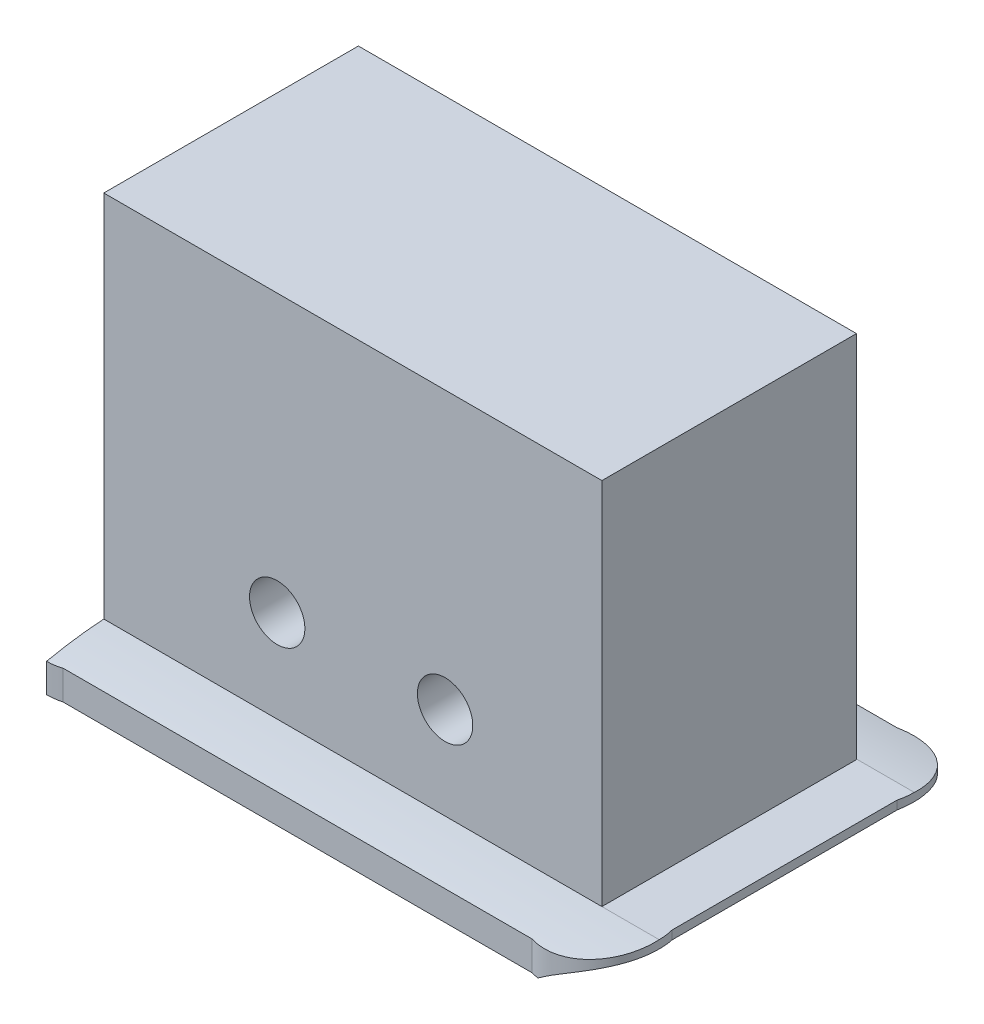
from build123d import *

# Parameters (mm, degrees)
SKETCH1_W               = 27
SKETCH1_H               = 13.8
SKETCH1_W_2             = 21
SKETCH1_H_2             = 7.8
BOSS_EXTRUDE1_DEPTH     = 22
SKETCH3_W               = 21
SKETCH3_H               = 7.8
BOSS_EXTRUDE2_DEPTH     = 2
SKETCH6_W               = 27
SKETCH6_H               = 13.8
BOSS_EXTRUDE3_DEPTH     = 2
SKETCH8_R               = 3
CUT_EXTRUDE2_DEPTH      = 5
CUT_EXTRUDE3_DEPTH      = 45
CUT_EXTRUDE5_DEPTH      = 45
CUT_EXTRUDE5_DEPTH_BACK = 45
SKETCH7_R               = 1.5
CUT_EXTRUDE6_DEPTH      = 4.10483504
CUT_EXTRUDE6_DEPTH_BACK = 17.904835039
SKETCH15_W              = 4.518403315
SKETCH15_H              = 4.307078744
CUT_EXTRUDE7_DEPTH      = 10
CUT_EXTRUDE7_DEPTH_BACK = 20


with BuildPart() as part:
    # Sketch1 → Boss-Extrude1 (new body)
    with BuildSketch(Plane(origin=(0, 0, 0), x_dir=(1, 0, 0), z_dir=(0, 1, 0))):
        with Locations((10.5, 3.9)):
            Rectangle(SKETCH1_W, SKETCH1_H)
        with Locations((10.5, 3.9)):
            Rectangle(SKETCH1_W_2, SKETCH1_H_2, mode=Mode.SUBTRACT)
    extrude(amount=BOSS_EXTRUDE1_DEPTH)

    # Sketch3 → Boss-Extrude2 (add)
    with BuildSketch(Plane(origin=(0, 22, 0), x_dir=(1, 0, 0), z_dir=(0, 1, 0))):
        with Locations((10.5, 3.9)):
            Rectangle(SKETCH3_W, SKETCH3_H)
    extrude(amount=-BOSS_EXTRUDE2_DEPTH)

    # Sketch6 → Boss-Extrude3 (add)
    with BuildSketch(Plane.XZ):
        with BuildLine():
            Line((-6, 2.2), (-6, -10))
            ThreePointArc((-6, -10), (-5.19544984, -12.99544984), (-2.2, -13.8))
            Line((-2.2, -13.8), (23.2, -13.8))
            ThreePointArc((23.2, -13.8), (26.19544984, -12.99544984), (27, -10))
            Line((27, -10), (27, 2.2))
            ThreePointArc((27, 2.2), (26.19544984, 5.19544984), (23.2, 6))
            Line((23.2, 6), (-2.2, 6))
            ThreePointArc((-2.2, 6), (-5.19544984, 5.19544984), (-6, 2.2))
        make_face()
        with Locations((10.5, -3.9)):
            Rectangle(SKETCH6_W, SKETCH6_H, mode=Mode.SUBTRACT)
    extrude(amount=-BOSS_EXTRUDE3_DEPTH)

    # Sketch8 → Cut-Extrude2 (cut)
    with BuildSketch(Plane.ZY.offset(3)):
        with Locations((-3.9, 16.816542633)):
            Circle(SKETCH8_R)
    extrude(amount=-CUT_EXTRUDE2_DEPTH, mode=Mode.SUBTRACT)

    # Sketch12 → Cut-Extrude3 (cut)
    with BuildSketch(Plane.ZY.offset(6)):
        with BuildLine():
            Line((3, 2), (6.104834939, 2))
            Line((6.104834939, 2), (6.104834939, 1.56677659))
            add(Edge.make_bspline(
                [(6.104834939, 1.56677659), (4.570942596, 1.898546139), (3, 2)],
                knots=[0, 0, 0, 1, 1, 1], degree=2))
        make_face()
        with BuildLine():
            Line((-13.933772202, 2), (-13.933772202, 1.56677659))
            add(Edge.make_bspline(
                [(-13.933772202, 1.56677659), (-12.399879859, 1.898546139), (-10.828937263, 2)],
                knots=[0, 0, 0, 1, 1, 1], degree=2))
            Line((-10.828937263, 2), (-13.933772202, 2))
        make_face()
    extrude(amount=-CUT_EXTRUDE3_DEPTH, mode=Mode.SUBTRACT)

    # Sketch13 → Cut-Extrude5 (cut, two sides)
    with BuildSketch(Plane(origin=(27, 0, -10), x_dir=(1, 0, 0), z_dir=(0, 0, 1))) as cut_extrude5_sk:
        with BuildLine():
            Line((-3.377880941, 0), (0.509598996, 0))
            Line((0.509598996, 0), (0.509598996, 1.57572602))
            Line((0.509598996, 1.57572602), (0.175576118, 1.57572602))
            add(Edge.make_bspline(
                [(-3.377880941, 0), (-2.337490472, 0.807111843), (-1.090367189, 1.274012221), (0.175576118, 1.57572602)],
                knots=[0, 0, 0, 0, 1, 1, 1, 1], degree=3))
        make_face()
    extrude(amount=CUT_EXTRUDE5_DEPTH, mode=Mode.SUBTRACT)
    extrude(cut_extrude5_sk.sketch, amount=-CUT_EXTRUDE5_DEPTH_BACK, mode=Mode.SUBTRACT)

    # Sketch7 → Cut-Extrude6 (cut, two sides)
    with BuildSketch(Plane(origin=(0, 0, -10.8), x_dir=(-1, 0, 0), z_dir=(0, 0, -1))) as cut_extrude6_sk:
        with Locations((-6.4, 7)):
            Circle(SKETCH7_R)
        with Locations((-15.5, 7)):
            Circle(SKETCH7_R)
    extrude(amount=CUT_EXTRUDE6_DEPTH, mode=Mode.SUBTRACT)
    extrude(cut_extrude6_sk.sketch, amount=-CUT_EXTRUDE6_DEPTH_BACK, mode=Mode.SUBTRACT)

    # Sketch15 → Cut-Extrude7 (cut, two sides)
    with BuildSketch(Plane.XY.offset(3)) as cut_extrude7_sk:
        with Locations((-5.259201658, -0.153539372)):
            Rectangle(SKETCH15_W, SKETCH15_H)
    extrude(amount=CUT_EXTRUDE7_DEPTH, mode=Mode.SUBTRACT)
    extrude(cut_extrude7_sk.sketch, amount=-CUT_EXTRUDE7_DEPTH_BACK, mode=Mode.SUBTRACT)


solid = part.part
